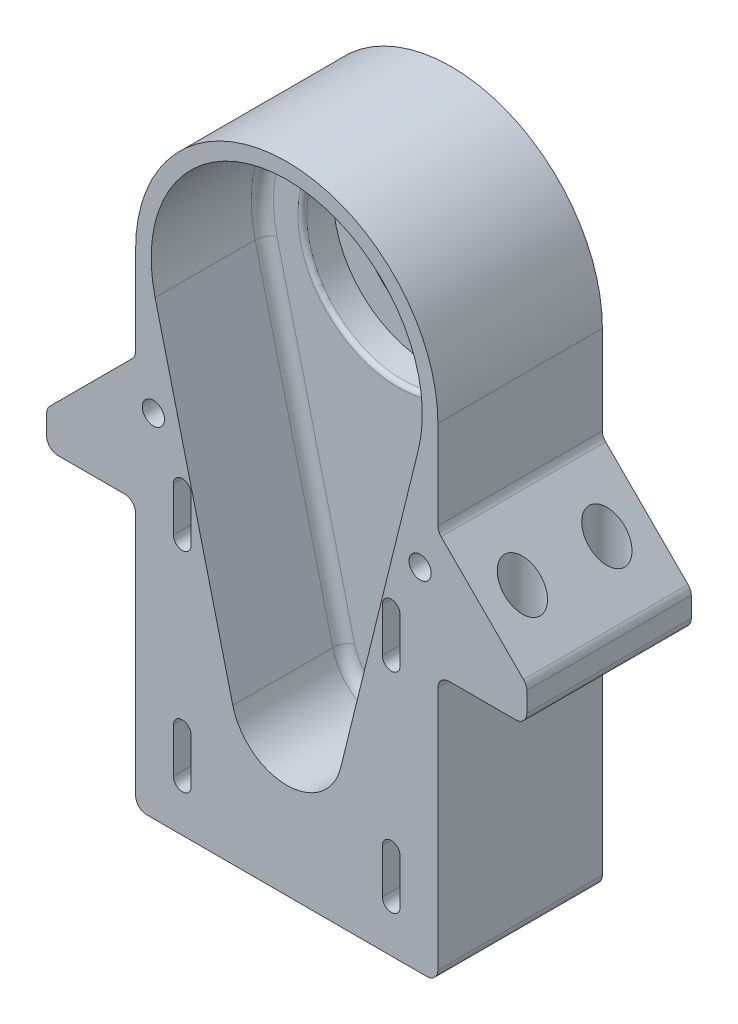
from build123d import *

# Parameters (mm, degrees)
BOSS_EXTRU_1_DEPTH      = 32
ESQUISSE1_7_R           = 15
BOSS_EXTRU_3_DEPTH      = 5
ESQUISSE1_8_R           = 21.5
BOSS_EXTRU_4_DEPTH      = 7
CONG_2_R                = 1
CONG_3_R                = 2.5
ESQUISSE2_R             = 2.5
ENL_V_MAT_EXTRU_1_DEPTH = 38
CONG_4_R                = 2.5
ESQUISSE3_R             = 4
ENL_V_MAT_EXTRU_2_DEPTH = 84


with BuildPart() as part:
    # Esquisse1 → Boss.-Extru.1 (new body)
    with BuildSketch(Plane.XY):
        with BuildLine():
            Line((34, -109), (34, -49))
            Line((34, -49), (54, -49))
            Line((54, -49), (54, -41))
            Line((54, -41), (34, -21))
            Line((34, -21), (34, 0))
            ThreePointArc((34, 0), (0, 34), (-34, 0))
            Line((-34, 0), (-34, -21))
            Line((-34, -21), (-54, -41))
            Line((-54, -41), (-54, -49))
            Line((-54, -49), (-34, -49))
            Line((-34, -49), (-34, -109))
            Line((-34, -109), (34, -109))
        make_face()
        with BuildLine():
            ThreePointArc((-21.5, -98.5), (-23.5, -100.5), (-25.5, -98.5))
            Line((-25.5, -98.5), (-25.5, -88.5))
            ThreePointArc((-25.5, -88.5), (-23.5, -86.5), (-21.5, -88.5))
            Line((-21.5, -88.5), (-21.5, -98.5))
        make_face(mode=Mode.SUBTRACT)
        with BuildLine():
            Line((-25.5, -51.5), (-25.5, -41.5))
            ThreePointArc((-25.5, -41.5), (-23.5, -39.5), (-21.5, -41.5))
            Line((-21.5, -41.5), (-21.5, -51.5))
            ThreePointArc((-21.5, -51.5), (-23.5, -53.5), (-25.5, -51.5))
        make_face(mode=Mode.SUBTRACT)
        with BuildLine():
            Line((25.5, -88.5), (25.5, -98.5))
            ThreePointArc((25.5, -98.5), (23.5, -100.5), (21.5, -98.5))
            Line((21.5, -98.5), (21.5, -88.5))
            ThreePointArc((21.5, -88.5), (23.5, -86.5), (25.5, -88.5))
        make_face(mode=Mode.SUBTRACT)
        with BuildLine():
            Line((21.5, -51.5), (21.5, -41.5))
            ThreePointArc((21.5, -41.5), (23.5, -39.5), (25.5, -41.5))
            Line((25.5, -41.5), (25.5, -51.5))
            ThreePointArc((25.5, -51.5), (23.5, -53.5), (21.5, -51.5))
        make_face(mode=Mode.SUBTRACT)
        with BuildLine():
            ThreePointArc((-29.608573083, -7.32), (0, 30.5), (29.608573083, -7.32))
            Line((29.608573083, -7.32), (12.1346611, -78))
            ThreePointArc((12.1346611, -78), (0, -87.5), (-12.1346611, -78))
            Line((-12.1346611, -78), (-29.608573083, -7.32))
        make_face(mode=Mode.SUBTRACT)
    extrude(amount=BOSS_EXTRU_1_DEPTH)

    # Esquisse1_7 → Boss.-Extru.3 (add)
    with BuildSketch(Plane.XY):
        with BuildLine():
            Line((34, -109), (34, -49))
            Line((34, -49), (54, -49))
            Line((54, -49), (54, -41))
            Line((54, -41), (34, -21))
            Line((34, -21), (34, 0))
            ThreePointArc((34, 0), (0, 34), (-34, 0))
            Line((-34, 0), (-34, -21))
            Line((-34, -21), (-54, -41))
            Line((-54, -41), (-54, -49))
            Line((-54, -49), (-34, -49))
            Line((-34, -49), (-34, -109))
            Line((-34, -109), (34, -109))
        make_face()
        with BuildLine():
            ThreePointArc((-21.5, -98.5), (-23.5, -100.5), (-25.5, -98.5))
            Line((-25.5, -98.5), (-25.5, -88.5))
            ThreePointArc((-25.5, -88.5), (-23.5, -86.5), (-21.5, -88.5))
            Line((-21.5, -88.5), (-21.5, -98.5))
        make_face(mode=Mode.SUBTRACT)
        with BuildLine():
            Line((-25.5, -51.5), (-25.5, -41.5))
            ThreePointArc((-25.5, -41.5), (-23.5, -39.5), (-21.5, -41.5))
            Line((-21.5, -41.5), (-21.5, -51.5))
            ThreePointArc((-21.5, -51.5), (-23.5, -53.5), (-25.5, -51.5))
        make_face(mode=Mode.SUBTRACT)
        with BuildLine():
            Line((25.5, -88.5), (25.5, -98.5))
            ThreePointArc((25.5, -98.5), (23.5, -100.5), (21.5, -98.5))
            Line((21.5, -98.5), (21.5, -88.5))
            ThreePointArc((21.5, -88.5), (23.5, -86.5), (25.5, -88.5))
        make_face(mode=Mode.SUBTRACT)
        with BuildLine():
            Line((25.5, -41.5), (25.5, -51.5))
            ThreePointArc((25.5, -51.5), (23.5, -53.5), (21.5, -51.5))
            Line((21.5, -51.5), (21.5, -41.5))
            ThreePointArc((21.5, -41.5), (23.5, -39.5), (25.5, -41.5))
        make_face(mode=Mode.SUBTRACT)
        Circle(ESQUISSE1_7_R, mode=Mode.SUBTRACT)
    extrude(amount=-BOSS_EXTRU_3_DEPTH)

    # Esquisse1_8 → Boss.-Extru.4 (add)
    with BuildSketch(Plane.XY):
        with BuildLine():
            Line((-29.608573083, -7.32), (-12.1346611, -78))
            ThreePointArc((-12.1346611, -78), (0, -87.5), (12.1346611, -78))
            Line((12.1346611, -78), (29.608573083, -7.32))
            ThreePointArc((29.608573083, -7.32), (0, 30.5), (-29.608573083, -7.32))
        make_face()
        Circle(ESQUISSE1_8_R, mode=Mode.SUBTRACT)
    extrude(amount=BOSS_EXTRU_4_DEPTH)

    # Congé2
    cong_2_edges = [part.edges().sort_by_distance(p)[0] for p in [
        (-21.5, 0, 7),
    ]]
    fillet(cong_2_edges, radius=CONG_2_R)

    # Congé3
    cong_3_edges = [part.edges().sort_by_distance(p)[0] for p in [
        (-20.871617091, -42.66, 7),
        (0, -87.5, 7),
        (20.871617091, -42.66, 7),
        (0, 30.5, 7),
    ]]
    fillet(cong_3_edges, radius=CONG_3_R)

    # Esquisse2 → Enlèv. mat.-Extru.1 (cut, through all)
    with BuildSketch(Plane(origin=(0, 0, -5), x_dir=(-1, 0, 0), z_dir=(0, 0, -1))):
        with Locations((30, -30)):
            Circle(ESQUISSE2_R)
        with Locations((-30, -30)):
            Circle(ESQUISSE2_R)
    extrude(amount=-ENL_V_MAT_EXTRU_1_DEPTH, mode=Mode.SUBTRACT)

    # Congé4
    cong_4_edges = [part.edges().sort_by_distance(p)[0] for p in [
        (34, -109, 13.5),
        (-34, -109, 13.5),
        (-34, -49, 13.5),
        (-54, -49, 13.5),
        (-54, -41, 13.5),
        (-34, -21, 13.5),
        (34, -21, 13.5),
        (54, -41, 13.5),
        (54, -49, 13.5),
        (34, -49, 13.5),
    ]]
    fillet(cong_4_edges, radius=CONG_4_R)

    # Esquisse3 → Enlèv. mat.-Extru.2 (cut, through all)
    with BuildSketch(Plane.XZ.offset(49)):
        with Locations((-44, 4)):
            Circle(ESQUISSE3_R)
        with Locations((44, 4)):
            Circle(ESQUISSE3_R)
        with Locations((44, 23)):
            Circle(ESQUISSE3_R)
        with Locations((-44, 23)):
            Circle(ESQUISSE3_R)
    extrude(amount=-ENL_V_MAT_EXTRU_2_DEPTH, mode=Mode.SUBTRACT)


solid = part.part
